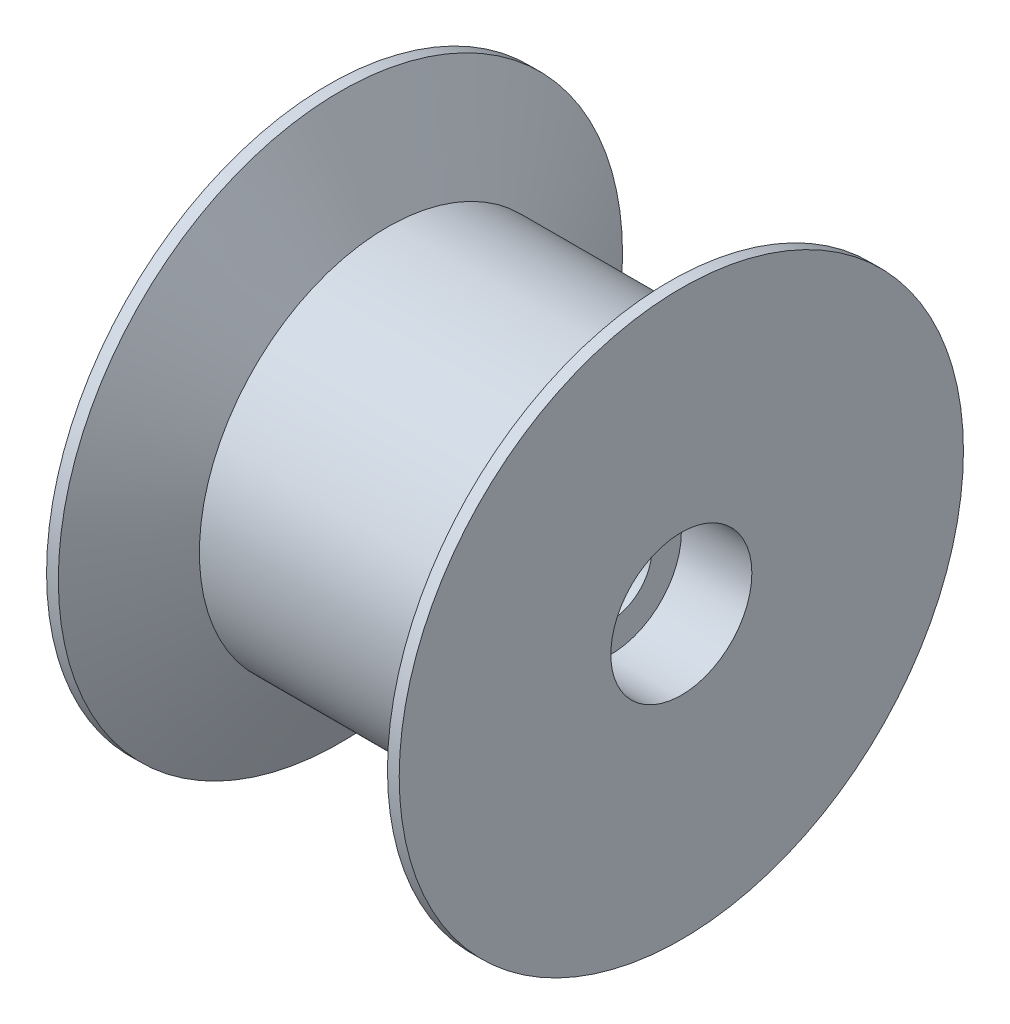
from build123d import *

# Parameters (mm, degrees)
ESQUISSE2_R                  = 3
ENL_V_MAT_EXTRU_1_DEPTH      = 3
ESQUISSE3_R                  = 1.75
ENL_V_MAT_EXTRU_2_DEPTH      = 4
ENL_V_MAT_EXTRU_2_DEPTH_BACK = 13


with BuildPart() as part:
    # Esquisse1 → Révolution1 (revolve)
    with BuildSketch(Plane.XY):
        Polygon((-7.5, 0), (7.5, 0), (7.5, 12), (7, 12), (5, 8), (-5, 8), (-7, 12), (-7.5, 12), align=None)
    revolve(axis=Axis((0, 0, 0), (-1, 0, 0)))

    # Esquisse2 → Enlèv. mat.-Extru.1 (cut)
    with BuildSketch(Plane(origin=(7.5, 0, 0), x_dir=(0, 0, -1), z_dir=(1, 0, 0))):
        Circle(ESQUISSE2_R)
    extrude(amount=-ENL_V_MAT_EXTRU_1_DEPTH, mode=Mode.SUBTRACT)

    # Esquisse3 → Enlèv. mat.-Extru.2 (cut, two sides)
    with BuildSketch(Plane(origin=(4.5, 0, 0), x_dir=(0, 0, -1), z_dir=(1, 0, 0))) as enl_v_mat_extru_2_sk:
        Circle(ESQUISSE3_R)
    extrude(amount=ENL_V_MAT_EXTRU_2_DEPTH, mode=Mode.SUBTRACT)
    extrude(enl_v_mat_extru_2_sk.sketch, amount=-ENL_V_MAT_EXTRU_2_DEPTH_BACK, mode=Mode.SUBTRACT)


solid = part.part
